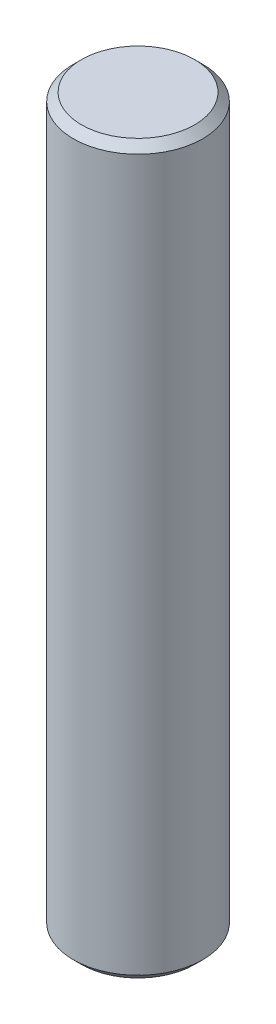
from build123d import *


with BuildPart() as part:
    # Sketch1 → Revolve1 (revolve)
    with BuildSketch(Plane.XY.offset(6)):
        Polygon((28.5, 34), (25, 34), (25, -11), (28.5, -11), (29, -10.5), (29, 33.5), align=None)
    revolve(axis=Axis((25, 34, 6), (0, -1, 0)))


solid = part.part
